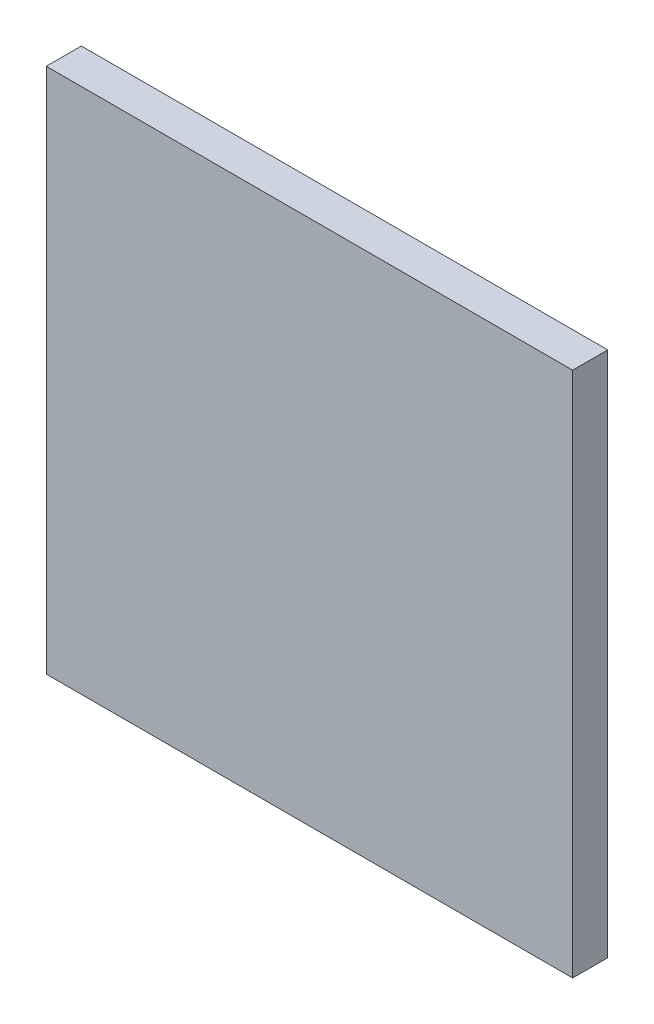
from build123d import *

# Parameters (mm, degrees)
SKETCH1_W           = 150
SKETCH1_H           = 150
BOSS_EXTRUDE1_DEPTH = 10


with BuildPart() as part:
    # Sketch1 → Boss-Extrude1 (new body)
    with BuildSketch(Plane.XY):
        with Locations((-0.176470588, 0)):
            Rectangle(SKETCH1_W, SKETCH1_H)
    extrude(amount=BOSS_EXTRUDE1_DEPTH)


solid = part.part
